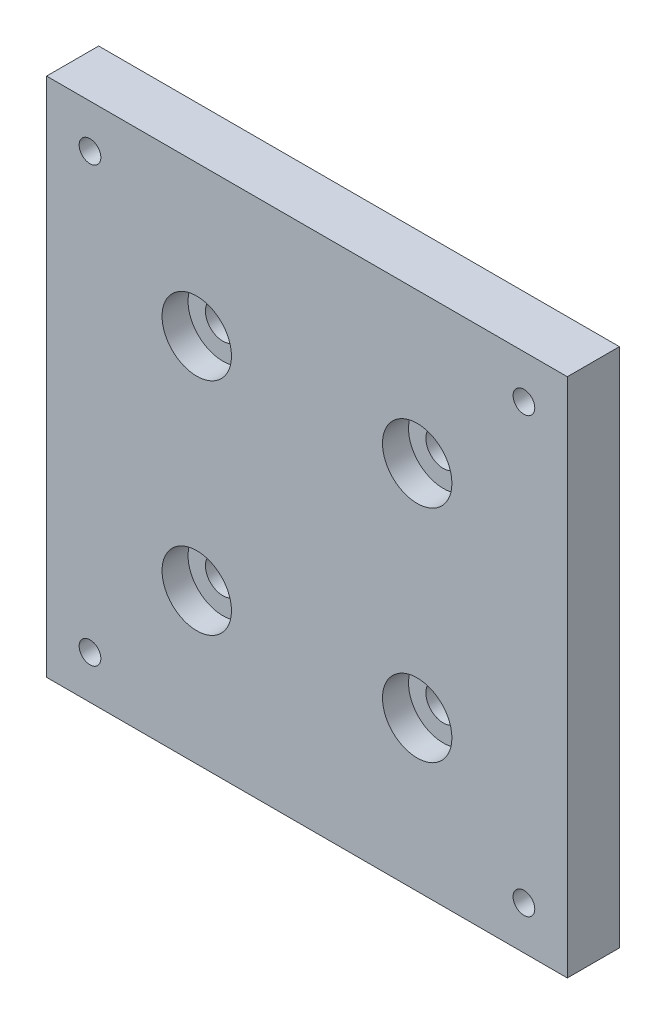
from build123d import *

# Parameters (mm, degrees)
SKETCH_1_W                = 60
SKETCH_1_H                = 60
EXTRUDE_1_DEPTH           = 6
HOLE_WIZARD_M3_1_D        = 2.5
HOLE_WIZARD_1_D           = 4
HOLE_WIZARD_1_CBORE_D     = 8
HOLE_WIZARD_1_CBORE_DEPTH = 3


with BuildPart() as part:
    # 草图1 → 凸台-拉伸1 (new body)
    with BuildSketch(Plane.XY):
        Rectangle(SKETCH_1_W, SKETCH_1_H)
    extrude(amount=EXTRUDE_1_DEPTH)

    # M3 螺纹孔1 (through all)
    with Locations(Plane(origin=(-25, 25, 6), x_dir=(1, 0, 0), z_dir=(0, 0, 1))):
        with Locations((0, 0), (50, 0), (50, -50), (0, -50)):
            Hole(HOLE_WIZARD_M3_1_D / 2)

    # 孔1 (through all)
    with Locations(Plane(origin=(-12.7, 12.7, 6), x_dir=(1, 0, 0), z_dir=(0, 0, 1))):
        with Locations((0, 0), (25.4, 0), (25.4, -25.4), (0, -25.4)):
            CounterBoreHole(HOLE_WIZARD_1_D / 2, HOLE_WIZARD_1_CBORE_D / 2, HOLE_WIZARD_1_CBORE_DEPTH)


solid = part.part
